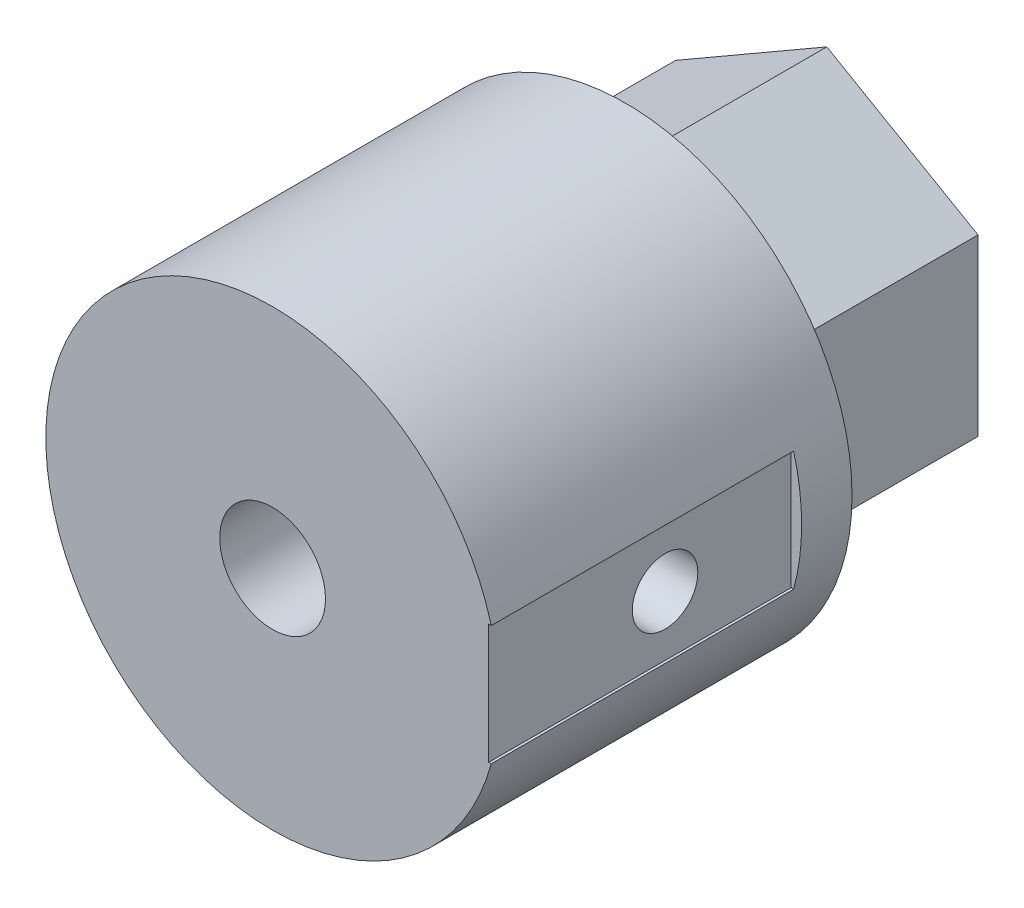
from build123d import *

# Parameters (mm, degrees)
BOSS_EXTRU_1_DEPTH      = 22
ESQUISSE2_R             = 1.7
ENL_V_MAT_EXTRU_1_DEPTH = 23
ESQUISSE3_R             = 9
ESQUISSE3_R_2           = 1.3
BOSS_EXTRU_2_DEPTH      = 14
ESQUISSE4_W             = 0.84262724
ESQUISSE4_H             = 4.751474998
ENL_V_MAT_EXTRU_2_DEPTH = 12
ESQUISSE5_R             = 1.3
ENL_V_MAT_EXTRU_3_DEPTH = 27
ESQUISSE6_R             = 2.1
ENL_V_MAT_EXTRU_4_DEPTH = 14


with BuildPart() as part:
    # Esquisse1 → Boss.-Extru.1 (new body)
    with BuildSketch(Plane.XY):
        Polygon((6, 3.464101615), (0, 6.92820323), (-6, 3.464101615), (-6, -3.464101615), (0, -6.92820323), (6, -3.464101615), align=None)
    extrude(amount=BOSS_EXTRU_1_DEPTH)

    # Esquisse2 → Enlèv. mat.-Extru.1 (cut)
    with BuildSketch(Plane.XY.offset(22)):
        Circle(ESQUISSE2_R)
    extrude(amount=-ENL_V_MAT_EXTRU_1_DEPTH, mode=Mode.SUBTRACT)

    # Esquisse3 → Boss.-Extru.2 (add)
    with BuildSketch(Plane.XY.offset(22)):
        Circle(ESQUISSE3_R)
        Circle(ESQUISSE3_R_2, mode=Mode.SUBTRACT)
    extrude(amount=-BOSS_EXTRU_2_DEPTH)

    # Esquisse4 → Enlèv. mat.-Extru.2 (cut)
    with BuildSketch(Plane.XY.offset(22)):
        with Locations((9, 0)):
            Rectangle(ESQUISSE4_W, ESQUISSE4_H)
    extrude(amount=-ENL_V_MAT_EXTRU_2_DEPTH, mode=Mode.SUBTRACT)

    # Esquisse5 → Enlèv. mat.-Extru.3 (cut)
    with BuildSketch(Plane(origin=(8.57868638, 0, 0), x_dir=(0, 0, -1), z_dir=(1, 0, 0))):
        with Locations((-15, 0)):
            Circle(ESQUISSE5_R)
    extrude(amount=-ENL_V_MAT_EXTRU_3_DEPTH, mode=Mode.SUBTRACT)

    # Esquisse6 → Enlèv. mat.-Extru.4 (cut)
    with BuildSketch(Plane.XY.offset(22)):
        Circle(ESQUISSE6_R)
    extrude(amount=-ENL_V_MAT_EXTRU_4_DEPTH, mode=Mode.SUBTRACT)


solid = part.part
